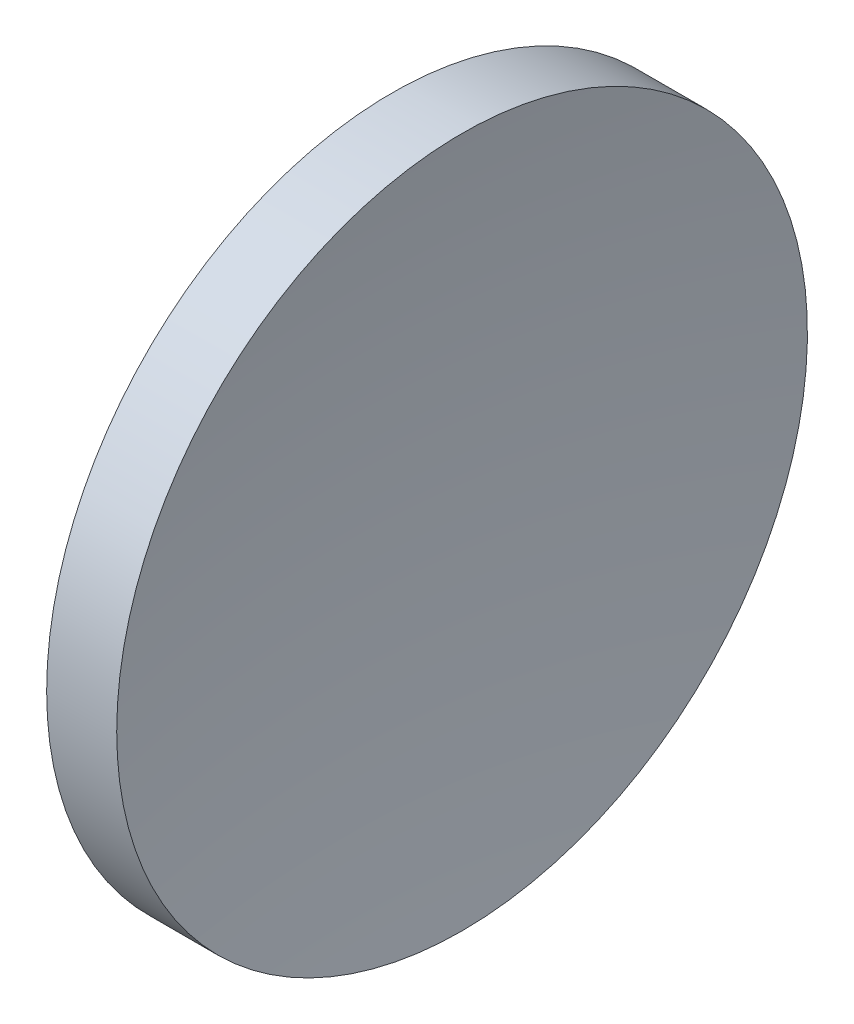
from build123d import *


with BuildPart() as part:
    # 草图1 → 旋转1 (revolve)
    with BuildSketch(Plane.XY, mode=Mode.PRIVATE) as revolve_1_sk:
        with BuildLine():
            Line((113.911931674, 65.155630457), (113.911931674, 85.155630457))
            Line((113.911931674, 85.155630457), (117.968817677, 85.155630457))
            ThreePointArc((117.968817677, 85.155630457), (116.80174104, 75.18588337), (116.411931674, 65.155630457))
            Line((116.411931674, 65.155630457), (113.911931674, 65.155630457))
        make_face()
    revolve(revolve_1_sk.sketch.rotate(Axis((105.621837124, 65.155630457, 0), (1, 0, 0)), 180), axis=Axis((105.621837124, 65.155630457, 0), (1, 0, 0)))  # turned: the seam where the file's is


solid = part.part
